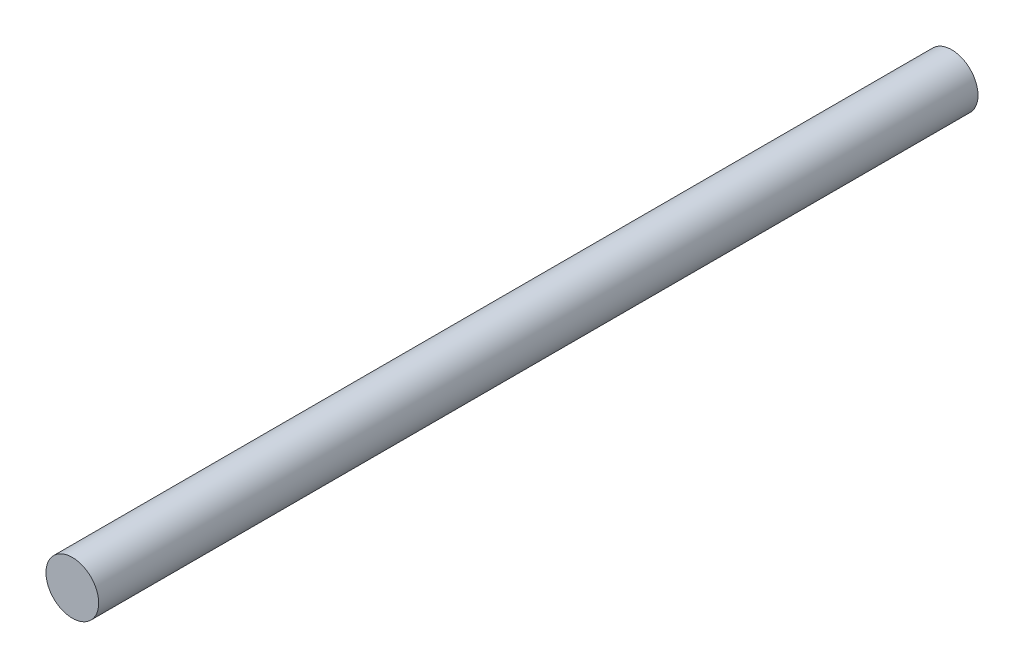
from build123d import *

# Parameters (mm, degrees)
SKETCH_1_R      = 3
EXTRUDE_1_DEPTH = 100


with BuildPart() as part:
    # Эскиз1 → Бобышка-Вытянуть1 (new body)
    with BuildSketch(Plane.XY):
        Circle(SKETCH_1_R)
    extrude(amount=EXTRUDE_1_DEPTH)


solid = part.part
